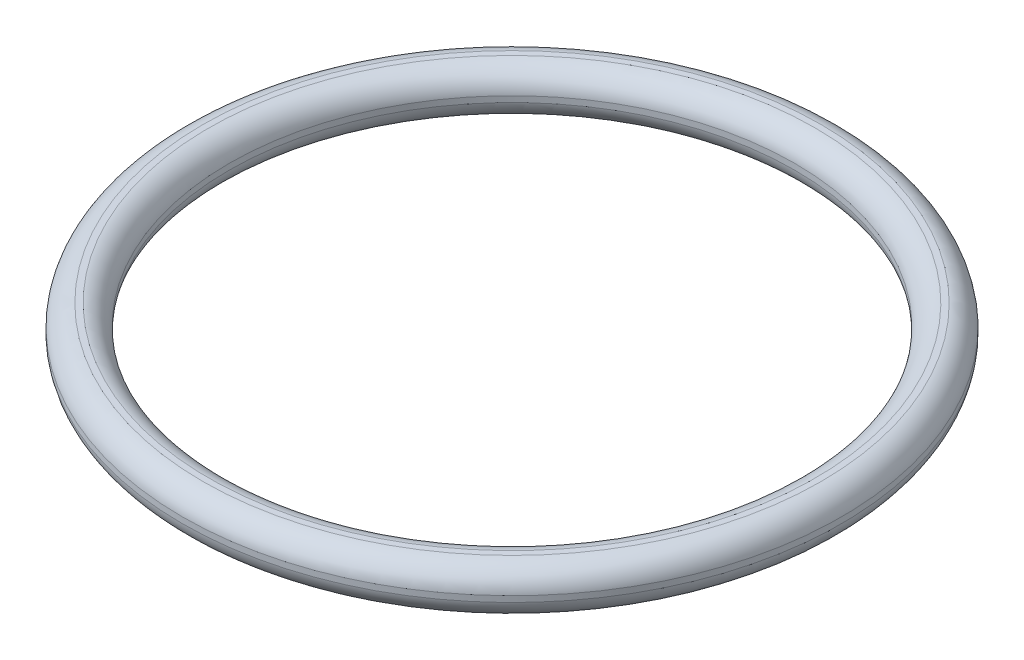
from build123d import *

# Parameters (mm, degrees)
SKETCH3_R   = 3.175
SKETCH6_W   = 6.3
SKETCH6_H   = 5
SKETCH6_W_2 = 5
SKETCH6_H_2 = 6.3
SKETCH6_W_3 = 38.125


with BuildPart() as part:
    # Sketch3 → Revolve1 (revolve)
    with BuildSketch(Plane.XY):
        with Locations((-41.275, 0)):
            Circle(SKETCH3_R)
    revolve(axis=Axis((0, -2.75, 0), (0, 1, 0)))

    # Sketch6 → Cut-Revolve1 (revolve, cut)
    with BuildSketch(Plane.XY):
        with Locations((-41.275, -5.65)):
            Rectangle(SKETCH6_W, SKETCH6_H)
        with Locations((-46.925, 0)):
            Rectangle(SKETCH6_W_2, SKETCH6_H_2)
        with Locations((-41.275, 5.65)):
            Rectangle(SKETCH6_W, SKETCH6_H)
        with Locations((-19.0625, 0)):
            Rectangle(SKETCH6_W_3, SKETCH6_H_2)
    revolve(axis=Axis((0, -2.75, 0), (0, 1, 0)), mode=Mode.SUBTRACT)


solid = part.part
